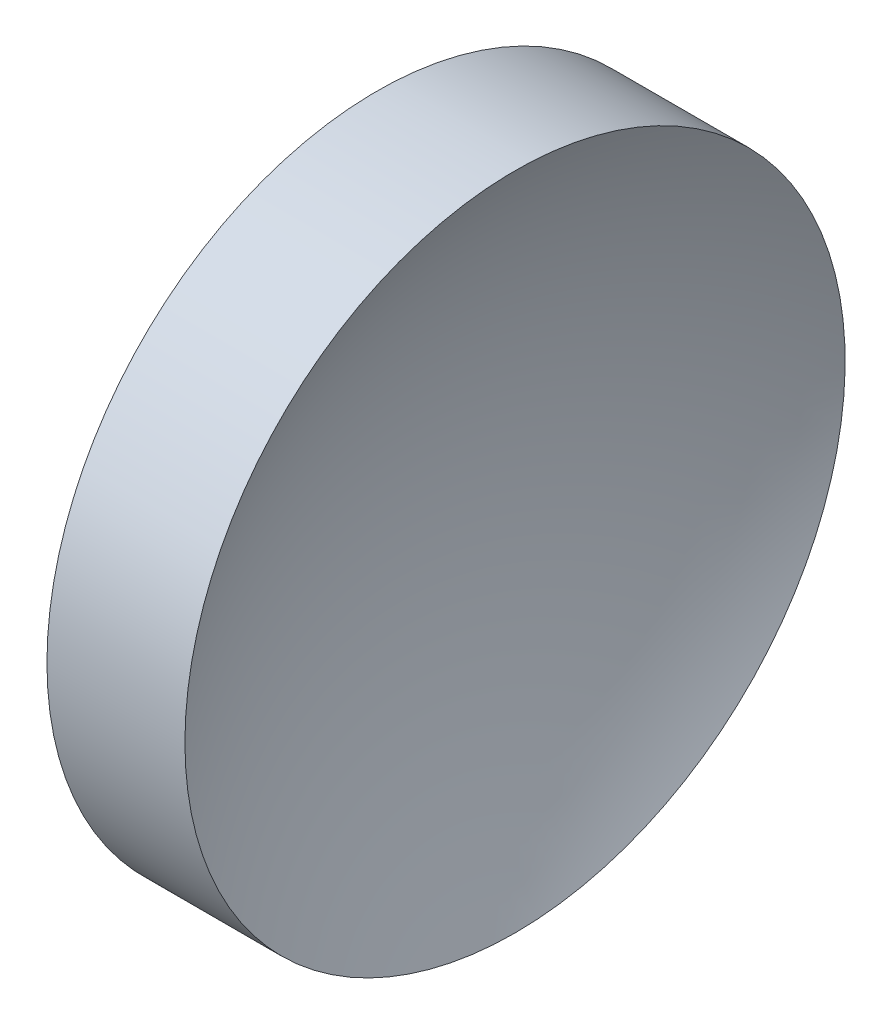
from build123d import *


with BuildPart() as part:
    # 草图1 → 旋转1 (revolve)
    with BuildSketch(Plane.XY, mode=Mode.PRIVATE) as revolve_1_sk:
        with BuildLine():
            Line((57.532337053, 32.610768129), (57.532337053, 45.110768129))
            Line((57.532337053, 45.110768129), (62.756952908, 45.110768129))
            ThreePointArc((62.756952908, 45.110768129), (60.351474495, 39.065381739), (59.532337053, 32.610768129))
            Line((59.532337053, 32.610768129), (57.532337053, 32.610768129))
        make_face()
    revolve(revolve_1_sk.sketch.rotate(Axis((56.10091508, 32.610768129, 0), (1, 0, 0)), 180), axis=Axis((56.10091508, 32.610768129, 0), (1, 0, 0)))  # turned: the seam where the file's is


solid = part.part
